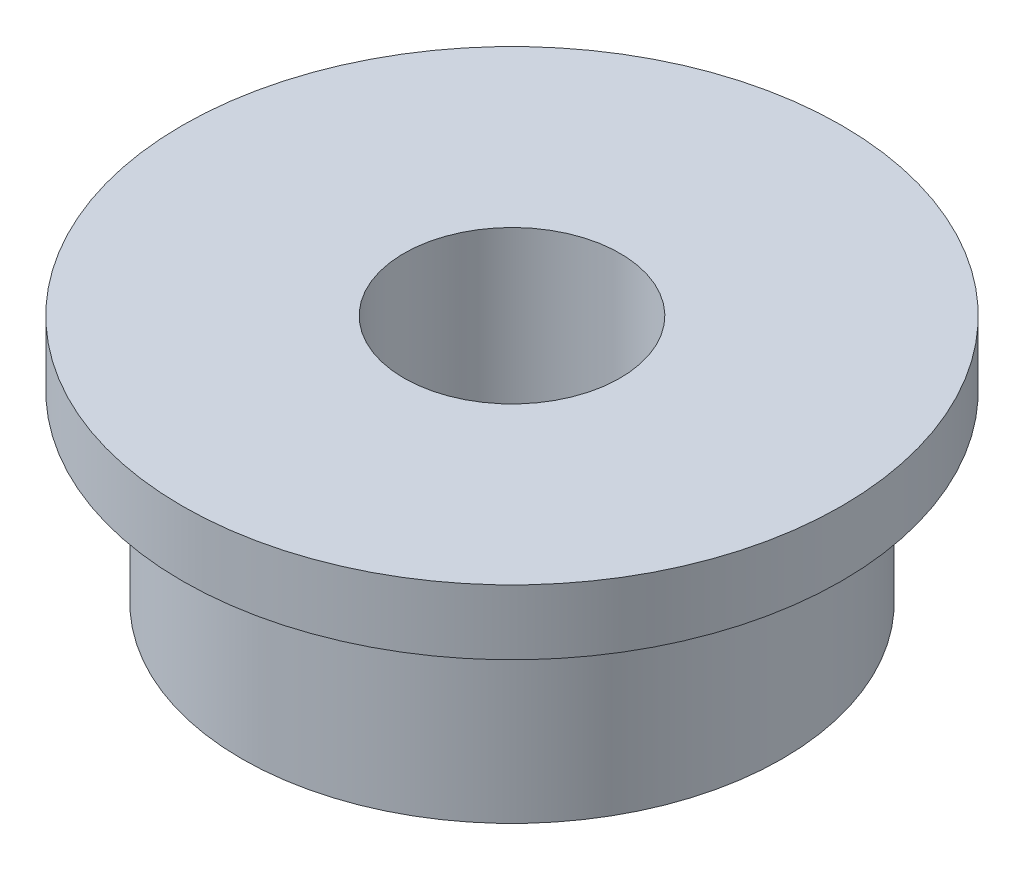
from build123d import *

# Parameters (mm, degrees)
SKETCH1_R           = 2.5
SKETCH1_R_2         = 1
BOSS_EXTRUDE1_DEPTH = 2.3
SKETCH2_R           = 3.05
SKETCH2_R_2         = 1
BOSS_EXTRUDE2_DEPTH = 0.6


with BuildPart() as part:
    # Sketch1 → Boss-Extrude1 (new body)
    with BuildSketch(Plane(origin=(0, 0, 0), x_dir=(1, 0, 0), z_dir=(0, 1, 0))):
        Circle(SKETCH1_R)
        Circle(SKETCH1_R_2, mode=Mode.SUBTRACT)
    extrude(amount=BOSS_EXTRUDE1_DEPTH)

    # Sketch2 → Boss-Extrude2 (add)
    with BuildSketch(Plane(origin=(0, 2.3, 0), x_dir=(1, 0, 0), z_dir=(0, 1, 0))):
        Circle(SKETCH2_R)
        Circle(SKETCH2_R_2, mode=Mode.SUBTRACT)
    extrude(amount=-BOSS_EXTRUDE2_DEPTH)


solid = part.part
